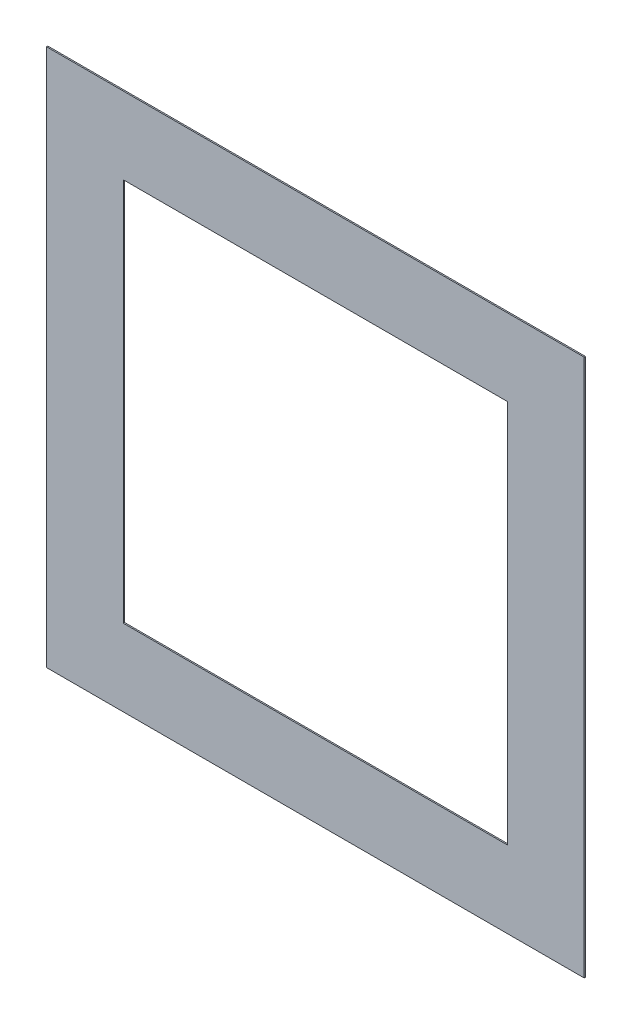
from build123d import *

# Parameters (mm, degrees)
SKETCH1_W           = 2100
SKETCH1_H           = 2100
BOSS_EXTRUDE1_DEPTH = 5
SKETCH2_W           = 1500
SKETCH2_H           = 1500
CUT_EXTRUDE1_DEPTH  = 6


with BuildPart() as part:
    # Sketch1 → Boss-Extrude1 (new body)
    with BuildSketch(Plane.XY):
        with Locations((55.479452055, -478.767123288)):
            Rectangle(SKETCH1_W, SKETCH1_H)
    extrude(amount=BOSS_EXTRUDE1_DEPTH)

    # Sketch2 → Cut-Extrude1 (cut, through all)
    with BuildSketch(Plane.XY.offset(5)):
        with Locations((55.479452055, -478.767123288)):
            Rectangle(SKETCH2_W, SKETCH2_H)
    extrude(amount=-CUT_EXTRUDE1_DEPTH, mode=Mode.SUBTRACT)


solid = part.part
